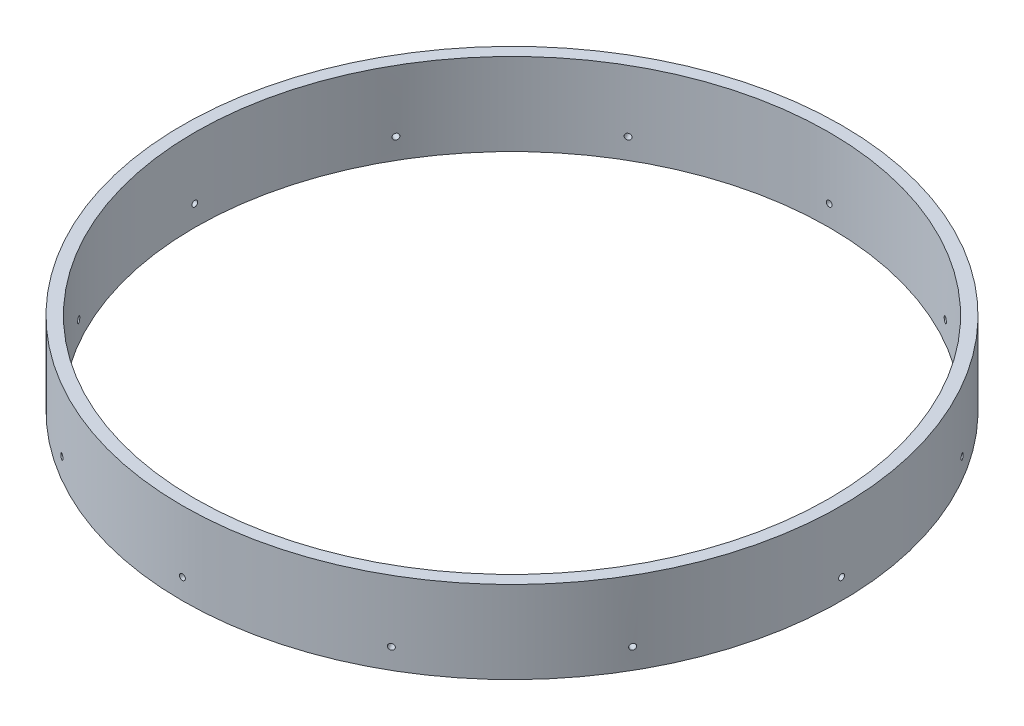
from build123d import *

# Parameters (mm, degrees)
SKETCH1_R           = 101.6
SKETCH1_R_2         = 82.55
BOSS_EXTRUDE1_DEPTH = 25.4
SKETCH2_R           = 97.79
SKETCH2_R_2         = 63.5
CUT_EXTRUDE1_DEPTH  = 50.8
SKETCH3_R           = 0.9
CUT_EXTRUDE2_DEPTH  = 254
CIRPATTERN1_COUNT   = 12


with BuildPart() as part:
    # Sketch1 → Boss-Extrude1 (new body)
    with BuildSketch(Plane(origin=(0, 0, 0), x_dir=(1, 0, 0), z_dir=(0, 1, 0))):
        Circle(SKETCH1_R)
        Circle(SKETCH1_R_2, mode=Mode.SUBTRACT)
    extrude(amount=BOSS_EXTRUDE1_DEPTH)

    # Sketch2 → Cut-Extrude1 (cut)
    with BuildSketch(Plane(origin=(0, 25.4, 0), x_dir=(1, 0, 0), z_dir=(0, 1, 0))):
        Circle(SKETCH2_R)
        Circle(SKETCH2_R_2, mode=Mode.SUBTRACT)
    extrude(amount=-CUT_EXTRUDE1_DEPTH, mode=Mode.SUBTRACT)

    # Sketch3 → Cut-Extrude2 (cut)
    with BuildSketch(Plane.XY):
        with Locations((0, 6.35)):
            Circle(SKETCH3_R)
    cut_extrude2 = extrude(amount=-CUT_EXTRUDE2_DEPTH, mode=Mode.SUBTRACT)

    # CirPattern1: Cut-Extrude2 ×12 about axis
    cirpattern1_axis = Axis((0, 25.4, 0), (0, 1, 0))
    for i in range(1, CIRPATTERN1_COUNT):
        add(cut_extrude2.rotate(cirpattern1_axis, i * 360 / CIRPATTERN1_COUNT), mode=Mode.SUBTRACT)


solid = part.part
